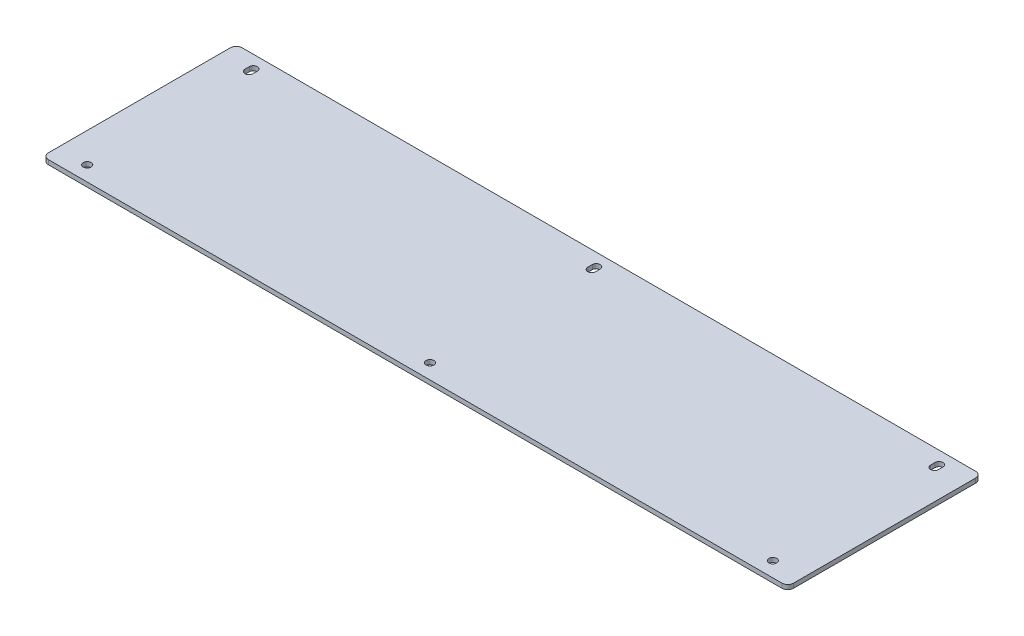
from build123d import *

# Parameters (mm, degrees)
SKETCH1_W                  = 500
SKETCH1_H                  = 130
BOSS_EXTRUDE1_DEPTH        = 3
FILLET1_R                  = 4
F_5_3_5_3_DIAMETER_HOLE1_D = 5.3
CUT_EXTRUDE1_DEPTH         = 4


with BuildPart() as part:
    # Sketch1 → Boss-Extrude1 (new body)
    with BuildSketch(Plane(origin=(0, 0, 0), x_dir=(1, 0, 0), z_dir=(0, 1, 0))):
        Rectangle(SKETCH1_W, SKETCH1_H)
    extrude(amount=BOSS_EXTRUDE1_DEPTH)

    # Fillet1
    fillet1_edges = [part.edges().sort_by_distance(p)[0] for p in [
        (250, 1.5, 65),
        (-250, 1.5, 65),
        (-250, 1.5, -65),
        (250, 1.5, -65),
    ]]
    fillet(fillet1_edges, radius=FILLET1_R)

    # Ø5.3 (5.3) Diameter Hole1 (through all)
    with Locations(Plane(origin=(0, 3, 0), x_dir=(1, 0, 0), z_dir=(0, 1, 0))):
        with Locations((230, 55), (-230, -55), (-230, 55), (230, -55), (0, 55), (0, -55)):
            Hole(F_5_3_5_3_DIAMETER_HOLE1_D / 2)

    # Sketch6 → Cut-Extrude1 (cut, through all)
    with BuildSketch(Plane(origin=(0, 3, 0), x_dir=(1, 0, 0), z_dir=(0, 1, 0))):
        with BuildLine():
            Line((-232.65, 53.5), (-232.65, 56.5))
            ThreePointArc((-232.65, 56.5), (-230, 59.15), (-227.35, 56.5))
            Line((-227.35, 56.5), (-227.35, 53.5))
            ThreePointArc((-227.35, 53.5), (-230, 50.85), (-232.65, 53.5))
        make_face()
        with BuildLine():
            Line((-2.65, 53.5), (-2.65, 56.5))
            ThreePointArc((-2.65, 56.5), (0, 59.15), (2.65, 56.5))
            Line((2.65, 56.5), (2.65, 53.5))
            ThreePointArc((2.65, 53.5), (0, 50.85), (-2.65, 53.5))
        make_face()
        with BuildLine():
            Line((227.35, 53.5), (227.35, 56.5))
            ThreePointArc((227.35, 56.5), (230, 59.15), (232.65, 56.5))
            Line((232.65, 56.5), (232.65, 53.5))
            ThreePointArc((232.65, 53.5), (230, 50.85), (227.35, 53.5))
        make_face()
    extrude(amount=-CUT_EXTRUDE1_DEPTH, mode=Mode.SUBTRACT)


solid = part.part
